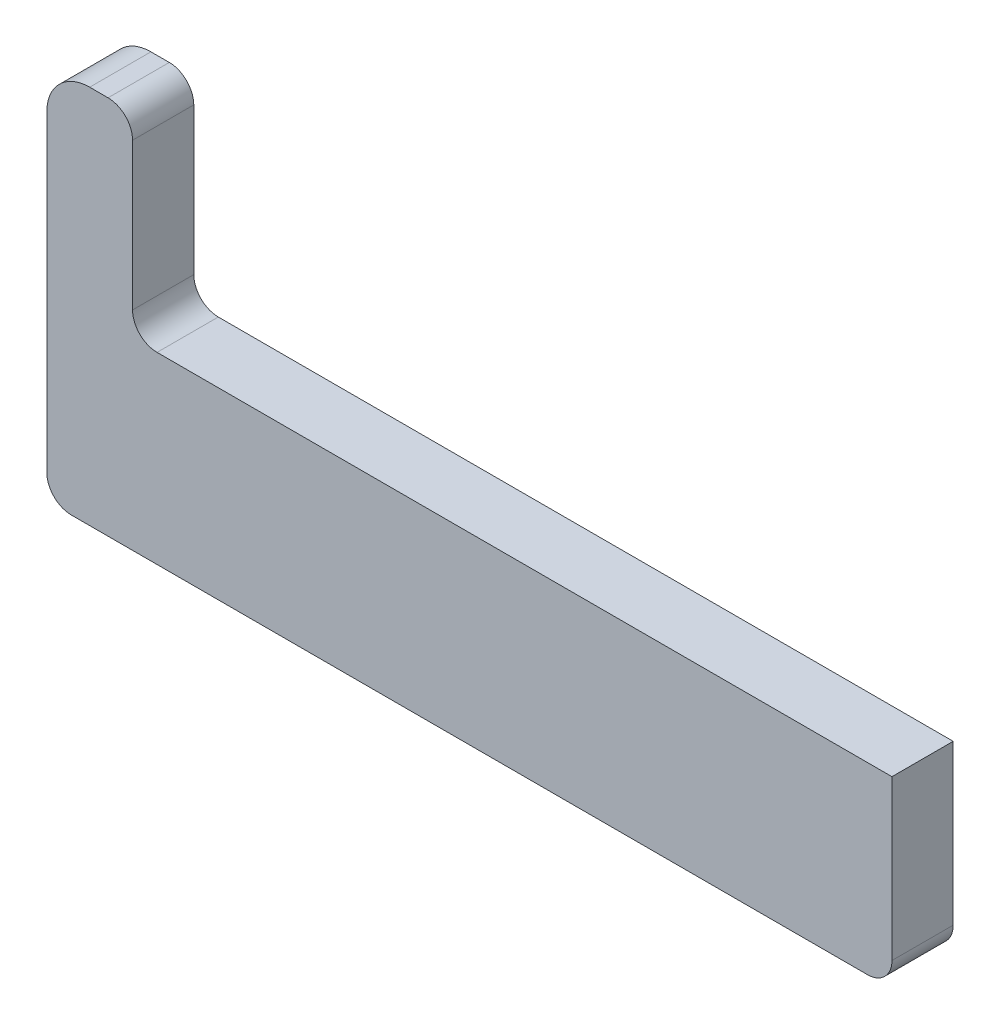
from build123d import *

# Parameters (mm, degrees)
BOSS_EXTRU_1_DEPTH = 5


with BuildPart() as part:
    # Esquisse1 → Boss.-Extru.1 (new body)
    with BuildSketch(Plane.XY):
        with BuildLine():
            Line((-2, 0), (-67, 0))
            ThreePointArc((-67, 0), (-68.414213562, 0.585786438), (-69, 2))
            Line((-69, 2), (-69, 27.5))
            ThreePointArc((-69, 27.5), (-67.974873734, 29.974873734), (-65.5, 31))
            Line((-65.5, 31), (-64, 31))
            ThreePointArc((-64, 31), (-62.585786438, 30.414213562), (-62, 29))
            Line((-62, 29), (-62, 17))
            ThreePointArc((-62, 17), (-61.414213562, 15.585786438), (-60, 15))
            Line((-60, 15), (0, 15))
            Line((0, 15), (0, 2))
            ThreePointArc((0, 2), (-0.585786438, 0.585786438), (-2, 0))
        make_face()
    extrude(amount=BOSS_EXTRU_1_DEPTH)


solid = part.part
